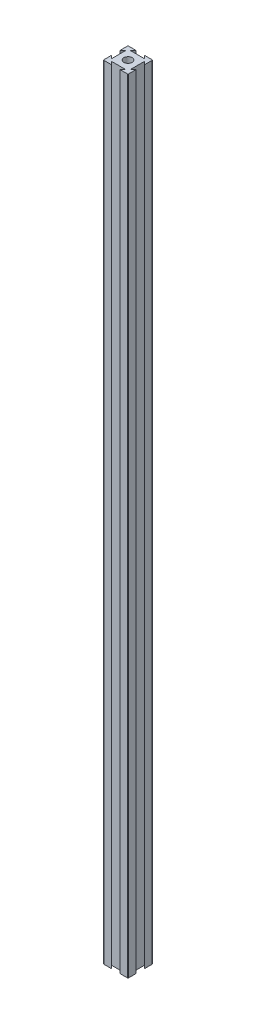
from build123d import *

# Parameters (mm, degrees)
SKETCH1_R           = 3.333333333
BOSS_EXTRUDE1_DEPTH = 635
FILLET4_R           = 0.508


with BuildPart() as part:
    # Sketch1 → Boss-Extrude1 (new body)
    with BuildSketch(Plane(origin=(0, 0, 0), x_dir=(1, 0, 0), z_dir=(0, 1, 0))):
        Polygon((4.285, 17.618333333), (6.666666667, 20), (0, 20), (0, 13.333333333), (2.381666667, 15.715), (2.381666667, 4.285), (0, 6.666666667), (0, 0), (6.666666667, 0), (4.285, 2.381666667), (15.715, 2.381666667), (13.333333333, 0), (20, 0), (20, 6.666666667), (17.618333333, 4.285), (17.618333333, 15.715), (20, 13.333333333), (20, 20), (13.333333333, 20), (15.715, 17.618333333), align=None)
        with Locations((10, 10)):
            Circle(SKETCH1_R, mode=Mode.SUBTRACT)
    extrude(amount=BOSS_EXTRUDE1_DEPTH)

    # Fillet4
    fillet4_edges = [part.edges().sort_by_distance(p)[0] for p in [
        (20, 317.5, 0),
        (0, 317.5, 0),
        (0, 317.5, -20),
        (20, 317.5, -20),
    ]]
    fillet(fillet4_edges, radius=FILLET4_R)


solid = part.part
